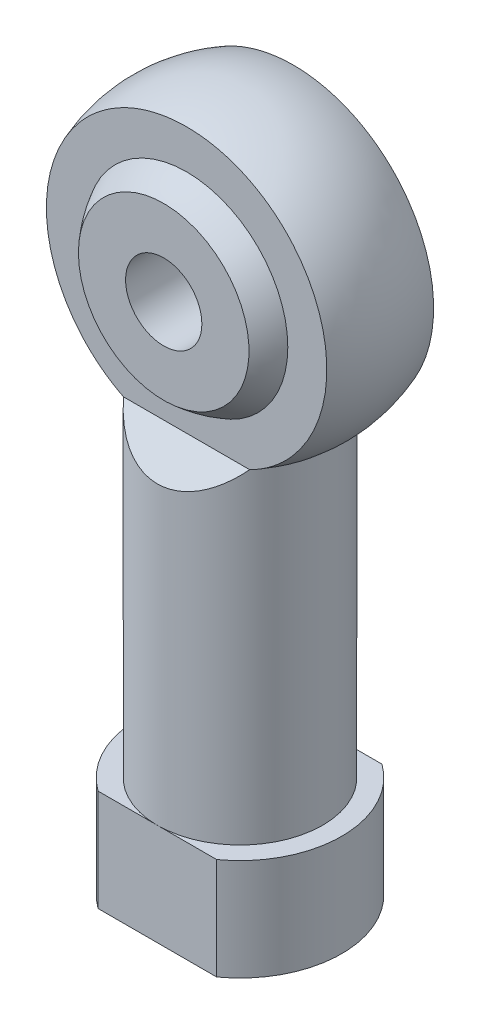
from build123d import *

# Parameters (mm, degrees)
CORTAR_EXTRUIR1_DEPTH      = 29.833660884
CORTAR_EXTRUIR1_DEPTH_BACK = 29.833660884
CROQUIS2_W                 = 3.8
CROQUIS2_H                 = 10.824175058
CROQUIS2_W_2               = 0.75
CROQUIS2_H_2               = 4
CORTAR_EXTRUIR2_DEPTH      = 29.580062981
CORTAR_EXTRUIR2_DEPTH_BACK = 29.580062981
CROQUIS4_W                 = 1.877516853
CROQUIS4_H                 = 6.743313928
CORTAR_EXTRUIR3_DEPTH      = 29.410077437
CORTAR_EXTRUIR3_DEPTH_BACK = 29.410077437
CROQUIS5_R                 = 1.5
TALADRO_ROSCADO_M31_D      = 2.5
TALADRO_ROSCADO_M31_DEPTH  = 14
TALADRO_ROSCADO_M31_TIP    = 0.751075774


with BuildPart() as part:
    # Croquis1 → Revolución1 (revolve)
    with BuildSketch(Plane.XY):
        with BuildLine():
            Line((0, 0), (0, 17.2))
            ThreePointArc((0, 17.2), (4.5, 21.7), (0, 26.2))
            Line((0, 26.2), (0, 27.6))
            ThreePointArc((0, 27.6), (5.65078016, 23.396668376), (3.25, 16.775824942))
            Line((3.25, 16.775824942), (3.25, 4))
            Line((3.25, 4), (4, 4))
            Line((4, 4), (4, 0))
            Line((4, 0), (0, 0))
        make_face()
    revolve(axis=Axis((0, 0, 0), (0, 1, 0)))

    # Croquis2 → Cortar-Extruir1 (cut, two sides: drawn at the far end of the back side and taken through both)
    with BuildSketch(Plane(origin=(0, 0, 0), x_dir=(0, 0, -1), z_dir=(1, 0, 0)).offset(-CORTAR_EXTRUIR1_DEPTH_BACK)):
        with Locations((-4, 22.187912471)):
            Rectangle(CROQUIS2_W, CROQUIS2_H)
        with Locations((4, 22.187912471)):
            Rectangle(CROQUIS2_W, CROQUIS2_H)
        Polygon((-3.25, 15.625824942), (-2.1, 16.775824942), (-3.25, 16.775824942), align=None)
        Polygon((3.25, 16.775824942), (2.1, 16.775824942), (3.25, 15.625824942), align=None)
        with Locations((3.625, 2)):
            Rectangle(CROQUIS2_W_2, CROQUIS2_H_2)
        with Locations((-3.625, 2)):
            Rectangle(CROQUIS2_W_2, CROQUIS2_H_2)
    extrude(amount=CORTAR_EXTRUIR1_DEPTH + CORTAR_EXTRUIR1_DEPTH_BACK, mode=Mode.SUBTRACT)

    # Croquis3 → Revolución2 (revolve)
    with BuildSketch(Plane.XY):
        with BuildLine():
            Line((0, 26.2), (0, 17.2))
            ThreePointArc((0, 17.2), (-4.5, 21.7), (0, 26.2))
        make_face()
    revolve(axis=Axis((0, 26.2, 0), (0, -1, 0)))

    # Croquis4 → Cortar-Extruir2 (cut, two sides: drawn at the far end of the back side and taken through both)
    with BuildSketch(Plane(origin=(0, 0, 0), x_dir=(0, 0, -1), z_dir=(1, 0, 0)).offset(-CORTAR_EXTRUIR2_DEPTH_BACK)):
        with Locations((-3.938758427, 21.717554998)):
            Rectangle(CROQUIS4_W, CROQUIS4_H)
        with Locations((3.938758427, 21.717554998)):
            Rectangle(CROQUIS4_W, CROQUIS4_H)
    extrude(amount=CORTAR_EXTRUIR2_DEPTH + CORTAR_EXTRUIR2_DEPTH_BACK, mode=Mode.SUBTRACT)

    # Croquis5 → Cortar-Extruir3 (cut, two sides: drawn at the far end of the back side and taken through both)
    with BuildSketch(Plane.XY.offset(-CORTAR_EXTRUIR3_DEPTH_BACK)):
        with Locations((0, 21.7)):
            Circle(CROQUIS5_R)
    extrude(amount=CORTAR_EXTRUIR3_DEPTH + CORTAR_EXTRUIR3_DEPTH_BACK, mode=Mode.SUBTRACT)

    # Taladro roscado M31
    with Locations(Plane(origin=(0, 0, 0), x_dir=(-1, 0, 0), z_dir=(0, -1, 0))):
        with Locations((0, 0)):
            Hole(TALADRO_ROSCADO_M31_D / 2, depth=TALADRO_ROSCADO_M31_DEPTH)
            with Locations((0, 0, -(TALADRO_ROSCADO_M31_DEPTH + TALADRO_ROSCADO_M31_TIP / 2))):  # 118° drill point
                Cone(0, TALADRO_ROSCADO_M31_D / 2, TALADRO_ROSCADO_M31_TIP, mode=Mode.SUBTRACT)


solid = part.part
